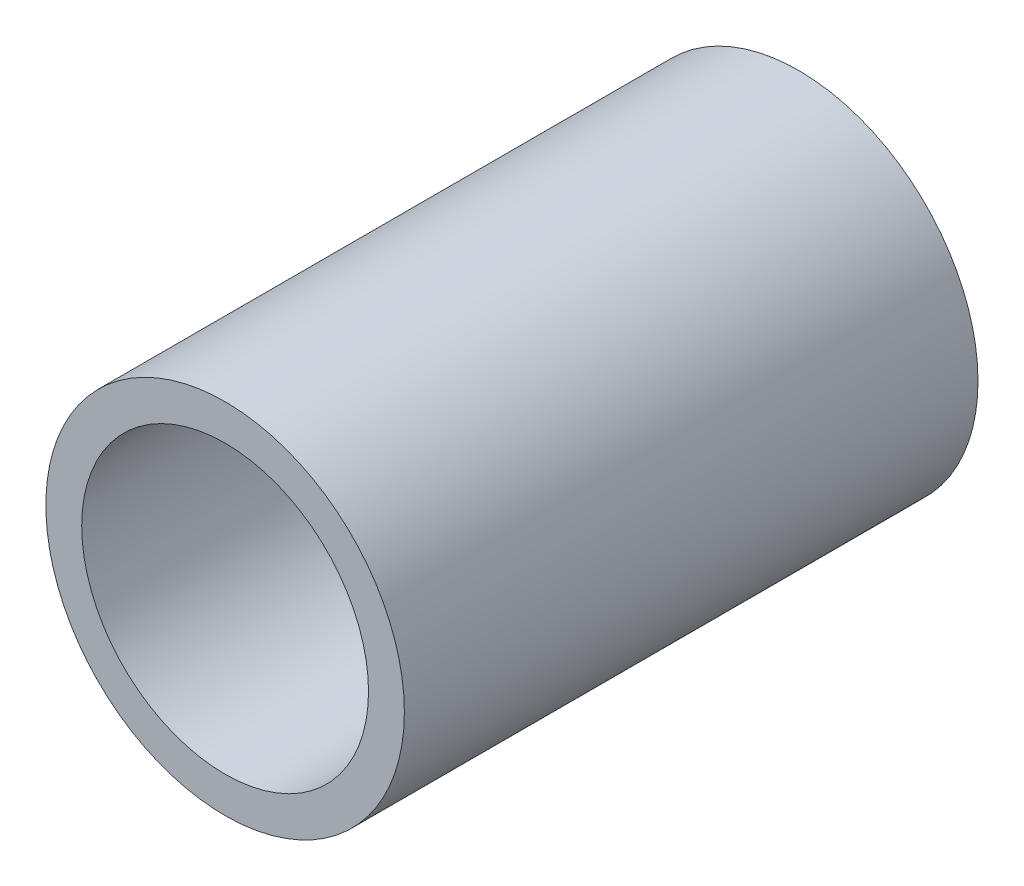
from build123d import *

# Parameters (mm, degrees)
SKETCH1_R           = 5
BOSS_EXTRUDE1_DEPTH = 1
SKETCH2_R           = 5
SKETCH2_R_2         = 4
BOSS_EXTRUDE3_DEPTH = 15


with BuildPart() as part:
    # Sketch1 → Boss-Extrude1 (new body)
    with BuildSketch(Plane.XY):
        Circle(SKETCH1_R)
    extrude(amount=BOSS_EXTRUDE1_DEPTH)

    # Sketch2 → Boss-Extrude3 (add)
    with BuildSketch(Plane.XY.offset(1)):
        Circle(SKETCH2_R)
        Circle(SKETCH2_R_2, mode=Mode.SUBTRACT)
    extrude(amount=BOSS_EXTRUDE3_DEPTH)


solid = part.part
